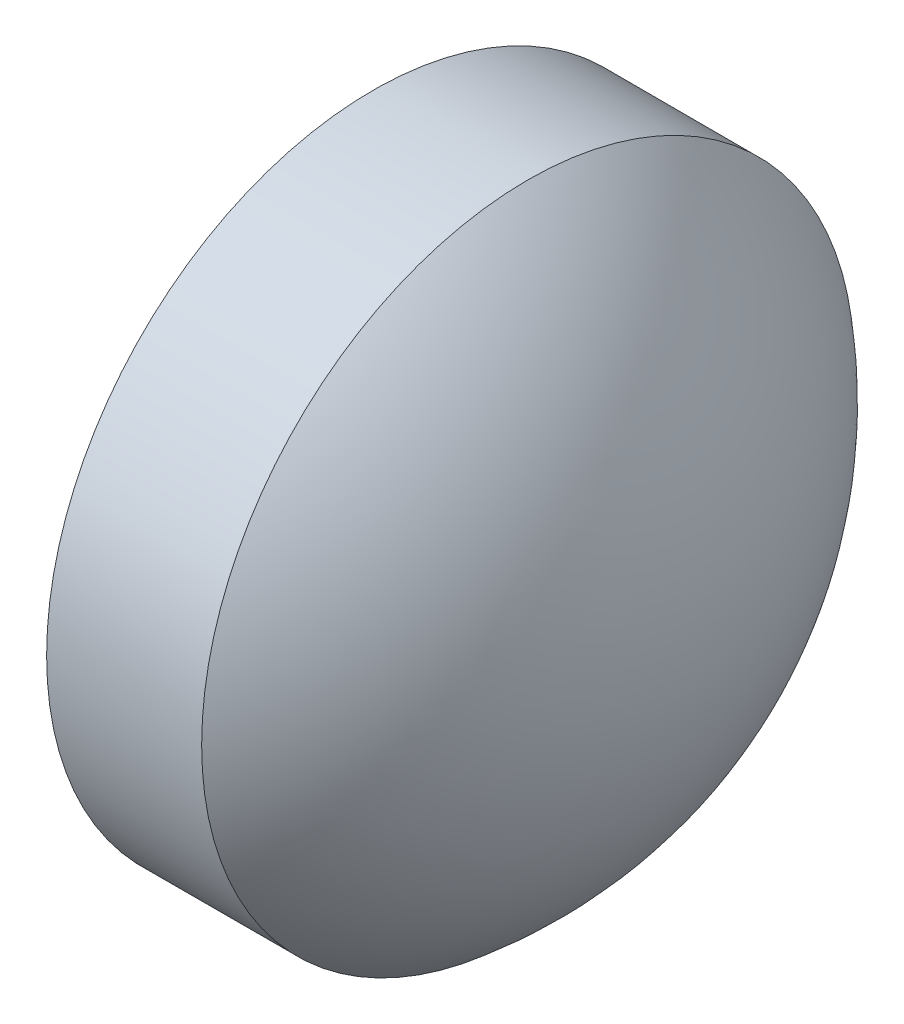
from build123d import *


with BuildPart() as part:
    # 草图1 → 旋转1 (revolve)
    with BuildSketch(Plane.XY):
        with BuildLine():
            Line((387.115955268, 29.368133797), (387.115955268, 31.368133797))
            Line((387.115955268, 31.368133797), (388.065955268, 31.368133797))
            ThreePointArc((388.065955268, 31.368133797), (388.766385776, 30.475213288), (389.015955268, 29.368133797))
            Line((389.015955268, 29.368133797), (387.115955268, 29.368133797))
        make_face()
    revolve(axis=Axis((386.768704709, 29.368133797, 0), (1, 0, 0)))


solid = part.part
